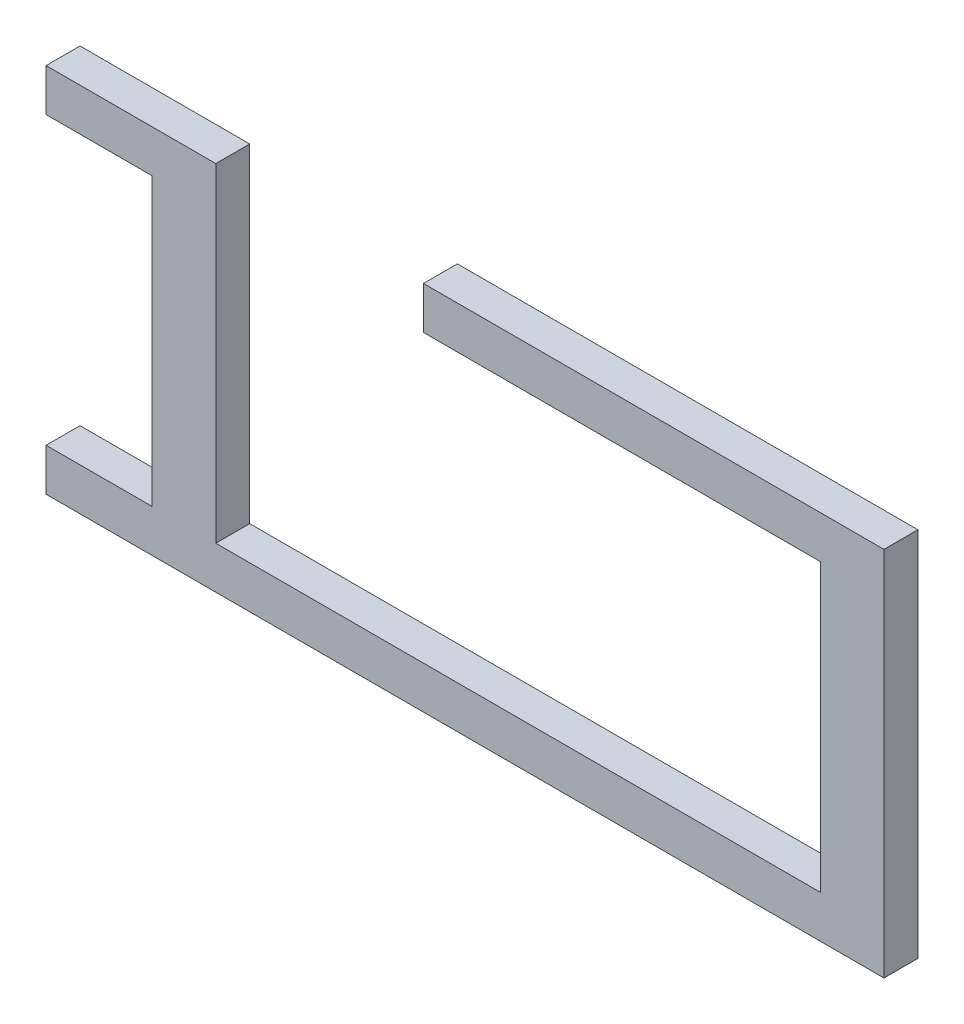
from build123d import *

# Parameters (mm, degrees)
EXTRUDE_1_DEPTH = 1.6


with BuildPart() as part:
    # 草图1 → 凸台-拉伸1 (new body)
    with BuildSketch(Plane.XY):
        Polygon((14.659609993, 3.20477089), (36.371935867, 3.20477089), (36.371935867, -14.29522911), (-3.128064133, -14.29522911), (-3.128064133, -12.29522911), (1.871935867, -12.29522911), (1.871935867, 1.20477089), (-3.128064133, 1.20477089), (-3.128064133, 3.20477089), (4.871935867, 3.20477089), (4.871935867, -12.29522911), (33.371935867, -12.29522911), (33.371935867, 1.20477089), (14.659609993, 1.20477089), align=None)
    extrude(amount=EXTRUDE_1_DEPTH)


solid = part.part
